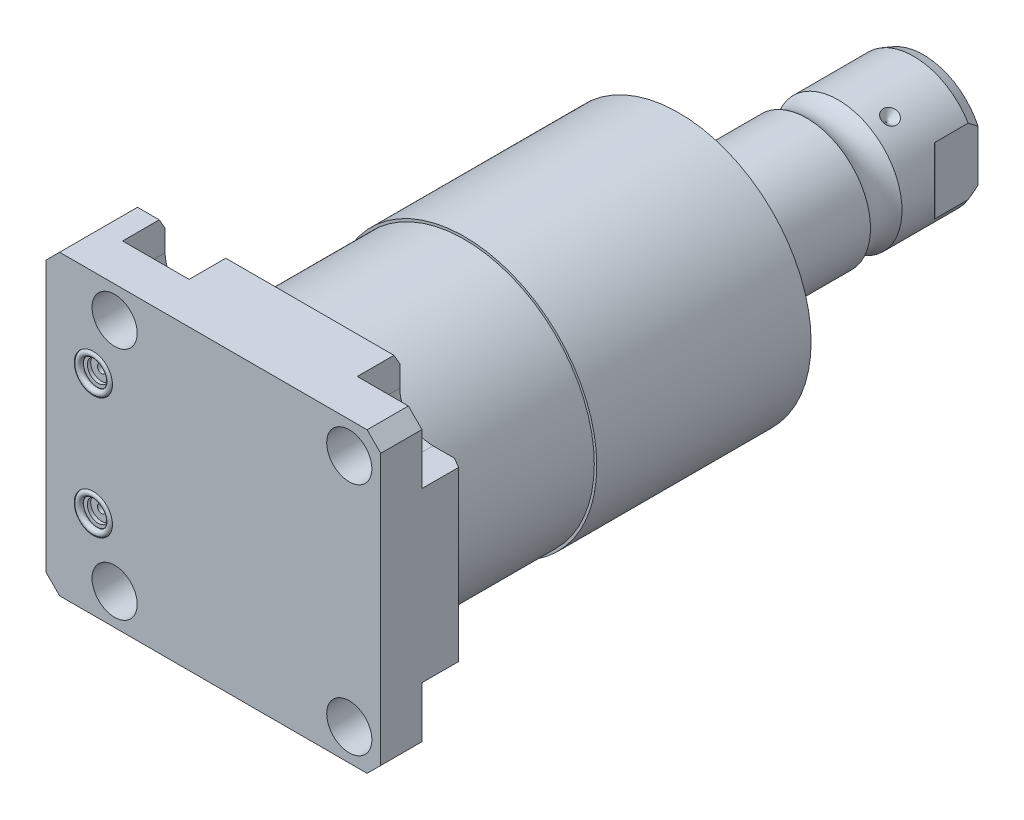
from build123d import *

# Parameters (mm, degrees)
SKETCH1_W               = 100
SKETCH1_H               = 88.9
EXTRUDE1_DEPTH          = 25.019
HOLE1_D                 = 13.487
CUT_EXTRUDE2_DEPTH      = 12.7
SKETCH6_R               = 5.7023
CUT_EXTRUDE3_DEPTH      = 1.4478
SKETCH7_R               = 3.2512
CUT_EXTRUDE4_DEPTH      = 1.016
SKETCH8_R               = 1.2446
CUT_EXTRUDE5_DEPTH      = 11.9888
SKETCH9_R               = 0.9271
CHAMFER1_SIZE           = 4.064
CHAMFER2_SIZE           = 3.0226
CHAMFER2_SIZE2          = 1.745098924
CIRPATTERN1_COUNT       = 3
CUT_EXTRUDE8_DEPTH      = 45.45
CUT_EXTRUDE8_DEPTH_BACK = 45.45


with BuildPart() as part:
    # Sketch1 → Extrude1 (new body)
    with BuildSketch(Plane.XY):
        with Locations((-5.55, 0)):
            Rectangle(SKETCH1_W, SKETCH1_H)
    extrude(amount=EXTRUDE1_DEPTH)

    # Hole1 (through all)
    with Locations(Plane(origin=(0, 0, 0), x_dir=(-1, 0, 0), z_dir=(0, 0, -1))):
        with Locations((-35.052, -35.052), (-35.052, 35.052), (35.052, 35.052), (35.052, -35.052)):
            Hole(HOLE1_D / 2)

    # Sketch3 → Cut-Extrude2 (cut)
    with BuildSketch(Plane(origin=(0, 0, 0), x_dir=(-1, 0, 0), z_dir=(0, 0, -1))):
        with BuildLine():
            Line((-35.052, -25.1205), (-44.45, -25.1205))
            Line((-44.45, -25.1205), (-44.45, -44.45))
            Line((-44.45, -44.45), (-25.1205, -44.45))
            Line((-25.1205, -44.45), (-25.1205, -35.052))
            ThreePointArc((-25.1205, -35.052), (-28.029369003, -28.029369003), (-35.052, -25.1205))
        make_face()
        with BuildLine():
            Line((-44.45, 25.1205), (-44.45, 44.45))
            Line((-44.45, 44.45), (-25.1205, 44.45))
            Line((-25.1205, 44.45), (-25.1205, 35.052))
            ThreePointArc((-25.1205, 35.052), (-28.029369003, 28.029369003), (-35.052, 25.1205))
            Line((-35.052, 25.1205), (-44.45, 25.1205))
        make_face()
        with BuildLine():
            Line((25.1205, 44.45), (25.1205, 35.052))
            ThreePointArc((25.1205, 35.052), (35.052, 25.1205), (44.9835, 35.052))
            Line((44.9835, 35.052), (44.9835, 44.45))
            Line((44.9835, 44.45), (25.1205, 44.45))
        make_face()
        with BuildLine():
            Line((44.9835, -44.45), (25.1205, -44.45))
            Line((25.1205, -44.45), (25.1205, -35.052))
            ThreePointArc((25.1205, -35.052), (35.052, -25.1205), (44.9835, -35.052))
            Line((44.9835, -35.052), (44.9835, -44.45))
        make_face()
    extrude(amount=-CUT_EXTRUDE2_DEPTH, mode=Mode.SUBTRACT)

    # Sketch23 → Cut-Revolve5 (revolve, cut)
    with BuildSketch(Plane.XY.offset(12.014), mode=Mode.PRIVATE) as cut_revolve5_sk:
        Polygon((-55.55, -23.749), (-55.296, -23.749), (-55.296, -19.6596), (-54.5848, -18.9484), (-41.1228, -18.9484), (-41.1228, -13.0048), (-55.55, -13.0048), align=None)
    cut_revolve5 = revolve(cut_revolve5_sk.sketch.rotate(Axis((-11.939660979, -13.0048, 12.014), (-1, 0, 0)), 180), axis=Axis((-11.939660979, -13.0048, 12.014), (-1, 0, 0)), mode=Mode.SUBTRACT)  # turned: the seam where the file's is

    # Mirror1: Cut-Revolve5 across plane
    add(cut_revolve5.mirror(Plane.ZX), mode=Mode.SUBTRACT)

    # Sketch6 → Cut-Extrude3 (cut)
    with BuildSketch(Plane.XY.offset(25.019)):
        with Locations((-41.402, -18.11)):
            Circle(SKETCH6_R)
        with Locations((-41.402, 18.11)):
            Circle(SKETCH6_R)
    extrude(amount=-CUT_EXTRUDE3_DEPTH, mode=Mode.SUBTRACT)

    # Sketch7 → Cut-Extrude4 (cut)
    with BuildSketch(Plane.XY.offset(23.5712)):
        with Locations((-41.402, 18.11)):
            Circle(SKETCH7_R)
        with Locations((-41.402, -18.11)):
            Circle(SKETCH7_R)
    extrude(amount=-CUT_EXTRUDE4_DEPTH, mode=Mode.SUBTRACT)

    # Sketch8 → Cut-Extrude5 (cut)
    with BuildSketch(Plane.XY.offset(22.5552)):
        with Locations((-41.402, 18.11)):
            Circle(SKETCH8_R)
        with Locations((-41.402, -18.11)):
            Circle(SKETCH8_R)
    extrude(amount=-CUT_EXTRUDE5_DEPTH, mode=Mode.SUBTRACT)

    # Chamfer1
    chamfer1_edges = [part.edges().sort_by_distance(p)[0] for p in [
        (-55.55, 44.45, 12.5095),
        (44.45, 44.45, 18.8595),
        (44.45, -44.45, 18.8595),
        (-55.55, -44.45, 12.5095),
    ]]
    chamfer(chamfer1_edges, length=CHAMFER1_SIZE)

    # Chamfer2
    chamfer2_edges = [part.edges().sort_by_distance(p)[0] for p in [
        (-48.23475, -44.45, 0),
        (44.45, 0, 0),
        (0, 44.45, 0),
        (-48.23475, 44.45, 0),
        (0, -44.45, 0),
    ]]
    chamfer2_side = [part.faces().sort_by_distance(p)[0] for p in [
        (-6.590555374, 0, 0),
    ]]
    chamfer(chamfer2_edges, length=CHAMFER2_SIZE, length2=CHAMFER2_SIZE2, reference=chamfer2_side[0])

    # Sketch24 → Revolve4 (revolve)
    with BuildSketch(Plane(origin=(0, 0, 0), x_dir=(0, 0, -1), z_dir=(1, 0, 0)), mode=Mode.PRIVATE) as revolve4_sk:
        Polygon((0, 0), (0, 38.786), (44.45, 38.786), (44.45, 39.5225), (108.48388753, 39.5225), (112.268, 25.4), (112.268, 0), align=None)
    revolve(revolve4_sk.sketch.rotate(Axis((0, 0, 0), (0, 0, -1)), 90), axis=Axis((0, 0, 0), (0, 0, -1)))  # turned: the seam where the file's is

    # Sketch17 → Revolve3 (revolve)
    with BuildSketch(Plane(origin=(0, 0, 0), x_dir=(0, 0, -1), z_dir=(1, 0, 0)), mode=Mode.PRIVATE) as revolve3_sk:
        with BuildLine():
            Line((112.268, 0), (112.268, -19.05))
            Line((112.268, -19.05), (146.70290643, -19.05))
            ThreePointArc((146.70290643, -19.05), (151.41, -17.5006), (156.11709357, -19.05))
            Line((156.11709357, -19.05), (178.66399416, -19.05))
            Line((178.66399416, -19.05), (181.585, -17.98684082))
            Line((181.585, -17.98684082), (181.585, 0))
            Line((181.585, 0), (112.268, 0))
        make_face()
    revolve(revolve3_sk.sketch.rotate(Axis((0, 0, -130.8989), (0, 0, 1)), 270), axis=Axis((0, 0, -130.8989), (0, 0, 1)))  # turned: the seam where the file's is

    # Sketch28 → Cut-Revolve6 (revolve, cut)
    with BuildSketch(Plane(origin=(0, 0, 0), x_dir=(1, 0, 0), z_dir=(0, 1, 0)), mode=Mode.PRIVATE) as cut_revolve6_sk:
        Polygon((-19.05, 164.491), (-16.637, 162.078), (-19.05, 162.078), align=None)
    cut_revolve6 = revolve(cut_revolve6_sk.sketch.rotate(Axis((-34.306164512, 0, -162.078), (1, 0, 0)), 180), axis=Axis((-34.306164512, 0, -162.078), (1, 0, 0)), mode=Mode.SUBTRACT)  # turned: the seam where the file's is

    # CirPattern1: Cut-Revolve6 ×3 about axis
    cirpattern1_axis = Axis((0, 0, -130.8989), (0, 0, -1))
    for i in range(1, CIRPATTERN1_COUNT):
        add(cut_revolve6.rotate(cirpattern1_axis, i * 360 / CIRPATTERN1_COUNT), mode=Mode.SUBTRACT)

    # Sketch32 → Hole2 (revolve, cut)
    with BuildSketch(Plane(origin=(0, 0, -181.585), x_dir=(0, 1, 0), z_dir=(1, 0, 0))):
        Polygon((0, 0), (0, 29.566487704), (6.9342, 25.4), (6.9342, 0), align=None)
    revolve(axis=Axis((0, 0, -185.829199587), (0, 0, 1)), mode=Mode.SUBTRACT)

    # Sketch34 → Cut-Extrude8 (cut, two sides)
    with BuildSketch(Plane(origin=(0, 0, 0), x_dir=(0, 0, -1), z_dir=(0, 1, 0))) as cut_extrude8_sk:
        with BuildLine():
            Line((165.800868636, 19.05), (168.346183558, 16.504685078))
            ThreePointArc((168.346183558, 16.504685078), (168.593394643, 16.339503912), (168.885, 16.2815))
            Line((168.885, 16.2815), (181.585, 16.2815))
            Line((181.585, 16.2815), (181.585, 19.05))
            Line((181.585, 19.05), (165.800868636, 19.05))
        make_face()
        with BuildLine():
            Line((181.585, -19.05), (165.800868636, -19.05))
            Line((165.800868636, -19.05), (168.346183558, -16.504685078))
            ThreePointArc((168.346183558, -16.504685078), (168.593394643, -16.339503912), (168.885, -16.2815))
            Line((168.885, -16.2815), (181.585, -16.2815))
            Line((181.585, -16.2815), (181.585, -19.05))
        make_face()
    extrude(amount=CUT_EXTRUDE8_DEPTH, mode=Mode.SUBTRACT)
    extrude(cut_extrude8_sk.sketch, amount=-CUT_EXTRUDE8_DEPTH_BACK, mode=Mode.SUBTRACT)


with BuildPart() as body_2:
    # Sketch9 → Revolve1 (revolve)
    with BuildSketch(Plane(origin=(-41.656, 18.11, 23.5712), x_dir=(1, 0, 0), z_dir=(0, 1, 0))):
        with Locations((5.0292, -0.9271)):
            Circle(SKETCH9_R)
    revolve(axis=Axis((-41.402, 18.11, 25.51811), (0, 0, -1)))


with BuildPart() as body_3:
    # Mirror2: mirrored copy
    add(body_2.part.mirror(Plane.ZX))


solid = Compound([part.part, body_2.part, body_3.part])
